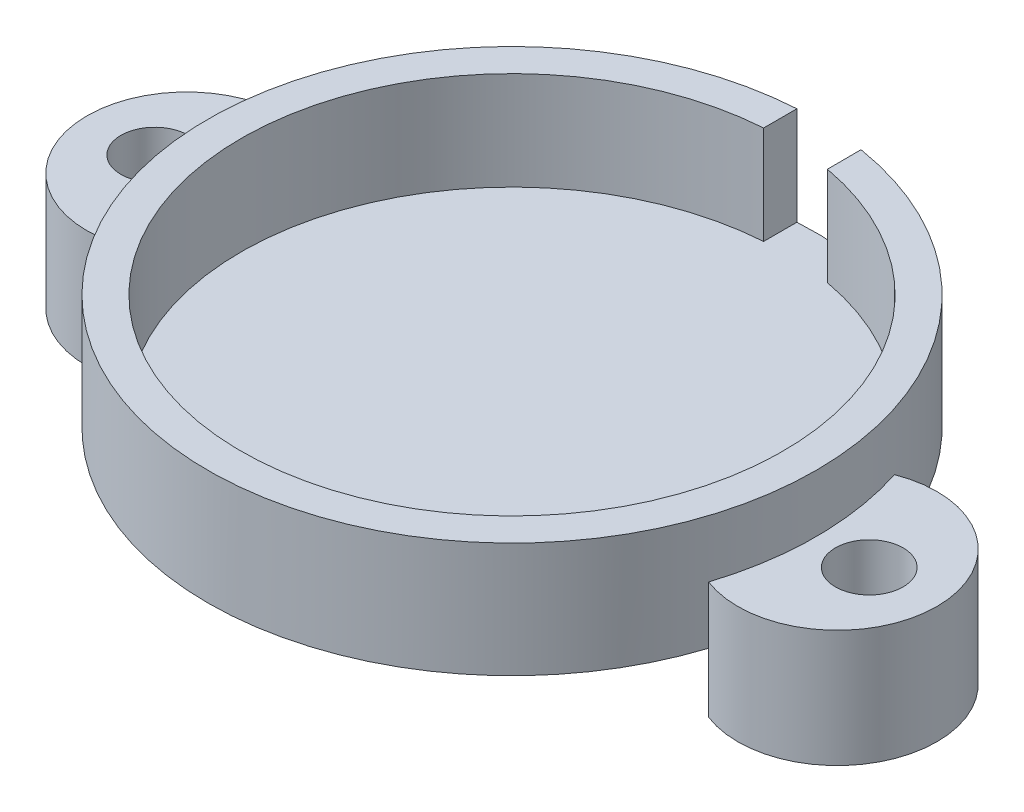
from build123d import *

# Parameters (mm, degrees)
SKETCH1_R                = 58.166
BOSS_EXTRUDE1_DEPTH      = 21.971
SKETCH3_R                = 51.816
CUT_EXTRUDE2_DEPTH       = 18.796
CUT_EXTRUDE7_DEPTH       = 18.796
SKETCH7_R                = 6.477
BOSS_EXTRUDE3_DEPTH      = 11.43
BOSS_EXTRUDE3_DEPTH_BACK = 10.9855


with BuildPart() as part:
    # Sketch1 → Boss-Extrude1 (new body)
    with BuildSketch(Plane(origin=(0, 0, 0), x_dir=(1, 0, 0), z_dir=(0, 1, 0))):
        Circle(SKETCH1_R)
    extrude(amount=BOSS_EXTRUDE1_DEPTH)

    # Sketch3 → Cut-Extrude2 (cut)
    with BuildSketch(Plane(origin=(0, 21.971, 0), x_dir=(1, 0, 0), z_dir=(0, 1, 0))):
        Circle(SKETCH3_R)
    extrude(amount=-CUT_EXTRUDE2_DEPTH, mode=Mode.SUBTRACT)

    # Sketch6 → Cut-Extrude7 (cut)
    with BuildSketch(Plane(origin=(0, 21.971, 0), x_dir=(1, 0, 0), z_dir=(0, 1, 0))):
        with BuildLine():
            Line((9.363048829, 50.963037318), (9.340756891, 57.411094892))
            ThreePointArc((9.340756891, 57.411094892), (2.903170649, 58.093503563), (-3.57037671, 58.056317194))
            Line((-3.57037671, 58.056317194), (-3.57037671, 51.692845406))
            ThreePointArc((-3.57037671, 51.692845406), (2.919232353, 51.733702153), (9.363048829, 50.963037318))
        make_face()
    extrude(amount=-CUT_EXTRUDE7_DEPTH, mode=Mode.SUBTRACT)

    # Sketch7 → Boss-Extrude3 (add, two sides)
    with BuildSketch(Plane.XZ) as boss_extrude3_sk:
        with BuildLine():
            ThreePointArc((55.382885714, -17.776938037), (81.28, 0), (55.382885714, 17.776938037))
            ThreePointArc((55.382885714, 17.776938037), (58.166, 0), (55.382885714, -17.776938037))
        make_face()
        with Locations((68.326, 0)):
            Circle(SKETCH7_R, mode=Mode.SUBTRACT)
        with BuildLine():
            ThreePointArc((-55.382885714, 17.776938037), (-81.28, 0), (-55.382885714, -17.776938037))
            ThreePointArc((-55.382885714, -17.776938037), (-58.166, 0), (-55.382885714, 17.776938037))
        make_face()
        with Locations((-68.323824172, 0)):
            Circle(SKETCH7_R, mode=Mode.SUBTRACT)
    extrude(amount=BOSS_EXTRUDE3_DEPTH)
    extrude(boss_extrude3_sk.sketch, amount=-BOSS_EXTRUDE3_DEPTH_BACK)


solid = part.part
